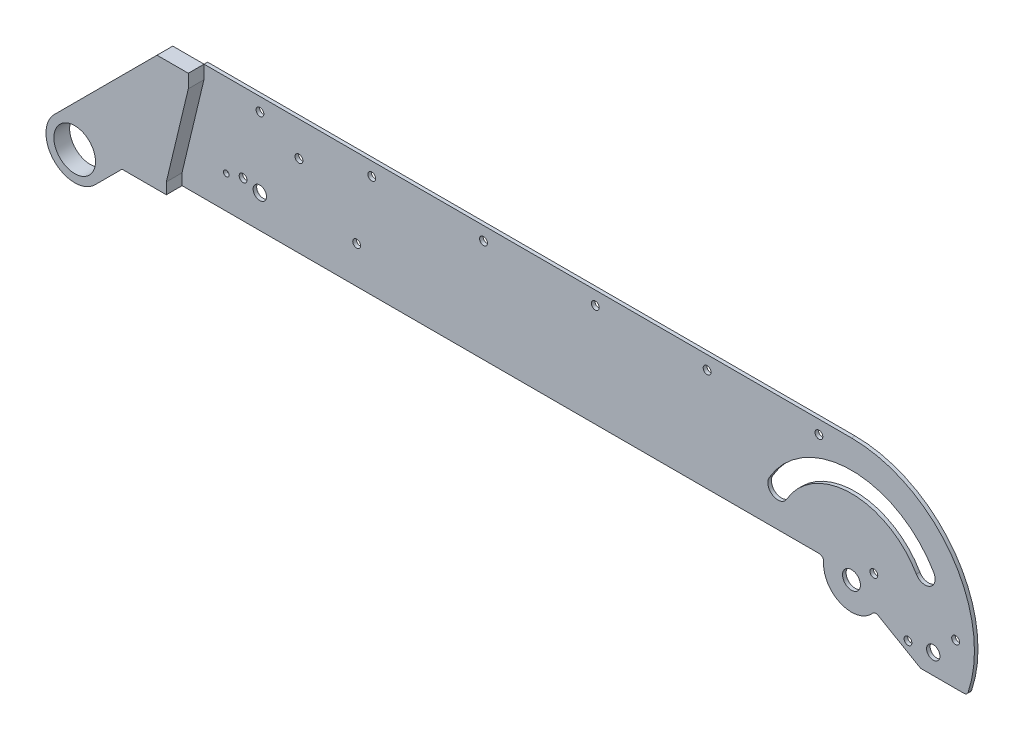
from build123d import *

# Parameters (mm, degrees)
SKETCH1_W             = 500
SKETCH1_H             = 150
SKETCH1_R             = 9.3
SKETCH1_R_2           = 3
SKETCH1_R_3           = 4
BOSS_EXTRUDE1_DEPTH   = 1.5875
SKETCH3_W             = 500
SKETCH3_H             = 150
CUT_EXTRUDE1_DEPTH    = 7
SKETCH4_R             = 9.3
CUT_EXTRUDE2_DEPTH    = 10
FILLET1_R             = 2
SKETCH5_R             = 1.75
SKETCH5_R_2           = 3
SKETCH5_R_3           = 1.25
CUT_EXTRUDE3_DEPTH    = 10
CUT_EXTRUDE4_START    = -10
SKETCH6_R             = 4
SKETCH6_R_2           = 3
SKETCH6_R_3           = 1.75
CUT_EXTRUDE4_DEPTH    = 10
SKETCH7_R             = 1.75
CUT_EXTRUDE5_DEPTH    = 246.38
BOSS_EXTRUDE2_DEPTH   = 7.045
SKETCH4_5_R           = 9.3
BOSS_EXTRUDE2_2_DEPTH = 7.045
BOSS_EXTRUDE9_DEPTH   = 7


with BuildPart() as part:
    # Sketch1 → Boss-Extrude1 (new body)
    with BuildSketch(Plane.XY):
        with Locations((200, 0)):
            Rectangle(SKETCH1_W, SKETCH1_H)
        Circle(SKETCH1_R, mode=Mode.SUBTRACT)
        with BuildLine():
            ThreePointArc((303.594020264, 21.24999987), (340.400100069, 42.5), (377.206179805, 21.249999751))
            ThreePointArc((377.206179805, 21.249999751), (375.559064779, 15.102885357), (369.411950518, 16.750000881))
            ThreePointArc((369.411950518, 16.750000881), (340.40010055, 33.5), (311.388250032, 16.750001833))
            ThreePointArc((311.388250032, 16.750001833), (305.241135638, 15.102885116), (303.594020264, 21.24999987))
        make_face(mode=Mode.SUBTRACT)
        with Locations((376.9688, -9.7841)):
            Circle(SKETCH1_R_2, mode=Mode.SUBTRACT)
        with Locations((340.4001, 0)):
            Circle(SKETCH1_R_3, mode=Mode.SUBTRACT)
    extrude(amount=BOSS_EXTRUDE1_DEPTH)

    # Sketch3 → Cut-Extrude1 (cut)
    with BuildSketch(Plane.XY.offset(1.5875)):
        with Locations((200, 0)):
            Rectangle(SKETCH3_W, SKETCH3_H)
        with BuildLine():
            Line((36.827355724, 55), (340.4001, 55))
            ThreePointArc((340.4001, 55), (385.445219047, 31.558473506), (392.093016219, -18.7841))
            Line((392.093016219, -18.7841), (371.332419214, -18.7841))
            Line((371.332419214, -18.7841), (350.803013897, -6.930323401))
            ThreePointArc((350.803013897, -6.930323401), (335.360003988, -11.438856245), (328.2654389, 3))
            Line((328.2654389, 3), (21.172644276, 3))
            Line((21.172644276, 3), (9.086322138, -9.086322138))
            ThreePointArc((9.086322138, -9.086322138), (-9.086322138, -9.086322138), (-9.086322138, 9.086322138))
            Line((-9.086322138, 9.086322138), (36.827355724, 55))
        make_face(mode=Mode.SUBTRACT)
    extrude(amount=-CUT_EXTRUDE1_DEPTH, mode=Mode.SUBTRACT)

    # Sketch4 → Cut-Extrude2 (cut)
    # profile 1 of 2: a face of its own
    with BuildSketch(Plane.XY.offset(1.5875)):
        Polygon((30.827355724, 49), (50.827355724, 49), (50.827355724, 55), (36.827355724, 55), align=None)
    # profile 2 of 2: a face of its own
    with BuildSketch(Plane.XY.offset(1.5875)):
        with BuildLine():
            Line((41, 3), (41, 8))
            Line((41, 8), (23.112698372, 8))
            Line((23.112698372, 8), (6.470027048, 24.642671324))
            Line((6.470027048, 24.642671324), (-9.086322138, 9.086322138))
            ThreePointArc((-9.086322138, 9.086322138), (-9.086322138, -9.086322138), (9.086322138, -9.086322138))
            Line((9.086322138, -9.086322138), (21.172644276, 3))
            Line((21.172644276, 3), (41, 3))
        make_face()
        Circle(SKETCH4_R, mode=Mode.SUBTRACT)
    extrude(amount=-CUT_EXTRUDE2_DEPTH, mode=Mode.SUBTRACT)

    # Fillet1
    fillet1_edges = [part.edges().sort_by_distance(p)[0] for p in [
        (392.093016219, -18.7841, 0.79375),
        (328.2654389, 3, 0.79375),
        (350.803013897, -6.930323401, 0.79375),
    ]]
    fillet(fillet1_edges, radius=FILLET1_R)

    # Sketch5 → Cut-Extrude3 (cut)
    with BuildSketch(Plane.XY.offset(1.5875)):
        with Locations((17.470027048, 19.642671324)):
            Circle(SKETCH5_R)
        with Locations((42.470027048, 39.642671324)):
            Circle(SKETCH5_R)
        with Locations((93.270027048, 39.642671324)):
            Circle(SKETCH5_R)
        with Locations((68.270027048, 19.642671324)):
            Circle(SKETCH5_R)
        with Locations((119.070027048, 19.642671324)):
            Circle(SKETCH5_R)
        with Locations((75.770027048, 17.642671324)):
            Circle(SKETCH5_R_2)
        with Locations((60.770027048, 17.642671324)):
            Circle(SKETCH5_R_3)
    extrude(amount=-CUT_EXTRUDE3_DEPTH, mode=Mode.SUBTRACT)

    # Sketch6 → Cut-Extrude4 (cut)
    with BuildSketch(Plane.XY.offset(1.5875).offset(CUT_EXTRUDE4_START)):
        with Locations((340.4001, 0)):
            Circle(SKETCH6_R)
        with Locations((376.9688, -9.7841)):
            Circle(SKETCH6_R_2)
        with Locations((350.4001, 7.5)):
            Circle(SKETCH6_R_3)
        with Locations((386.9688, 0)):
            Circle(SKETCH6_R_3)
        with Locations((365.670778247, -10.944141097)):
            Circle(SKETCH6_R_3)
    extrude(amount=CUT_EXTRUDE4_DEPTH, mode=Mode.SUBTRACT)

    # Sketch7 → Cut-Extrude5 (cut)
    with BuildSketch(Plane.XY.offset(1.5875)):
        with Locations((75.827355724, 49)):
            Circle(SKETCH7_R)
        with Locations((125.827355724, 49)):
            Circle(SKETCH7_R)
        with Locations((175.827355724, 49)):
            Circle(SKETCH7_R)
        with Locations((225.827355724, 49)):
            Circle(SKETCH7_R)
        with Locations((275.827355724, 49)):
            Circle(SKETCH7_R)
        with Locations((325.827355724, 49)):
            Circle(SKETCH7_R)
    extrude(amount=-CUT_EXTRUDE5_DEPTH, mode=Mode.SUBTRACT)


with BuildPart() as body_2:
    # Sketch4_5 → Boss-Extrude2 (new body)
    with BuildSketch(Plane.XY.offset(1.5875)):
        Polygon((30.827355724, 49), (50.827355724, 49), (50.827355724, 55), (36.827355724, 55), align=None)
    extrude(amount=BOSS_EXTRUDE2_DEPTH)



with BuildPart() as body_3:
    # Sketch4_5 → Boss-Extrude2 2 (new body)
    with BuildSketch(Plane.XY.offset(1.5875)):
        with BuildLine():
            Line((41, 3), (41, 8))
            Line((41, 8), (23.112698372, 8))
            Line((23.112698372, 8), (6.470027048, 24.642671324))
            Line((6.470027048, 24.642671324), (-9.086322138, 9.086322138))
            ThreePointArc((-9.086322138, 9.086322138), (-9.086322138, -9.086322138), (9.086322138, -9.086322138))
            Line((9.086322138, -9.086322138), (21.172644276, 3))
            Line((21.172644276, 3), (41, 3))
        make_face()
        Circle(SKETCH4_5_R, mode=Mode.SUBTRACT)
    extrude(amount=BOSS_EXTRUDE2_2_DEPTH)


with BuildPart() as body_2_1:
    add(body_2.part)

    add(body_3.part)  # Boss-Extrude9 merges body 3
    # Sketch9 → Boss-Extrude9 (add)
    with BuildSketch(Plane.XY.offset(8.6325)):
        Polygon((41, 8), (50.827355724, 49), (30.827355724, 49), (6.470027048, 24.642671324), (23.112698372, 8), align=None)
    extrude(amount=-BOSS_EXTRUDE9_DEPTH)


solid = Compound([part.part, body_2_1.part])
